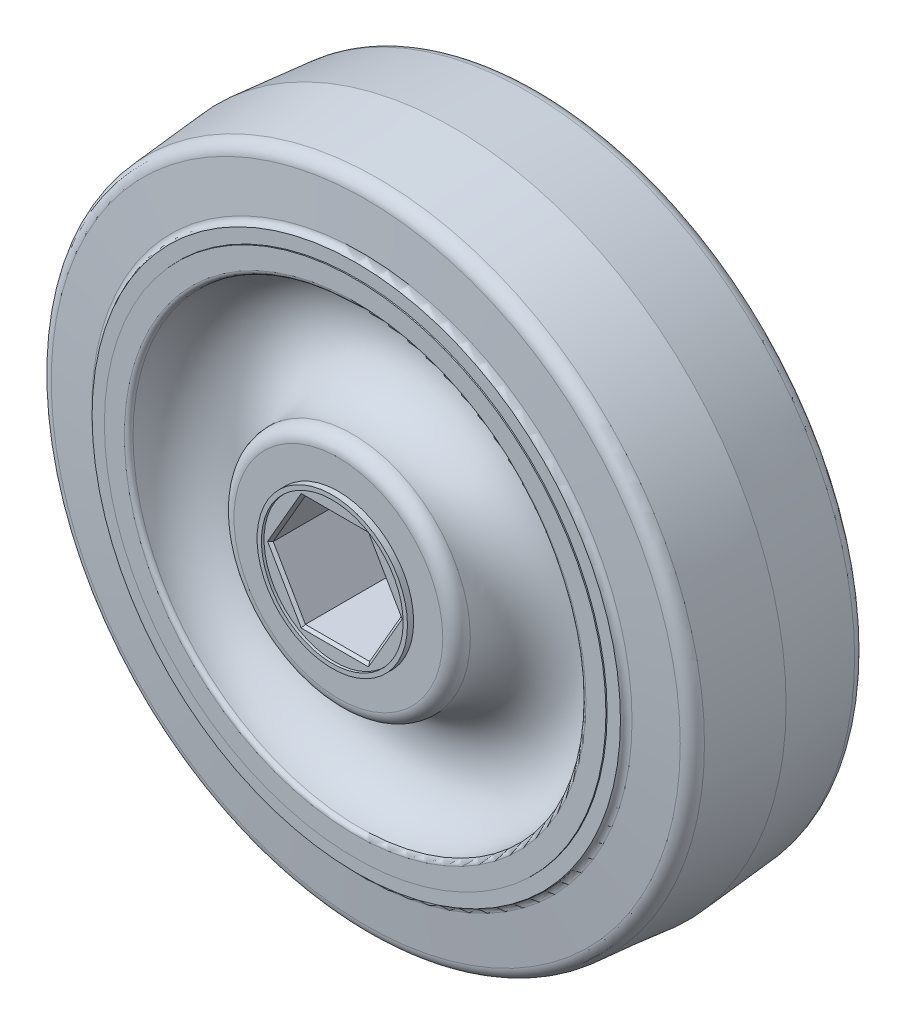
from build123d import *

# Parameters (mm, degrees)
SKETCH2_R           = 8.603491183
BOSS_EXTRUDE1_DEPTH = 0.70005
BOSS_EXTRUDE1_TAPER = 0.5
SKETCH3_R           = 8.603491183
BOSS_EXTRUDE2_DEPTH = 0.70005
BOSS_EXTRUDE2_TAPER = 0.5
CUT_EXTRUDE1_DEPTH  = 61.397248747
CHAMFER1_SIZE       = 0.3
FILLET1_R           = 0.508
FILLET2_R           = 1.524


with BuildPart() as part:
    # Sketch1 → Revolve1 (revolve)
    with BuildSketch(Plane(origin=(0, 0, 0), x_dir=(1, 0, 0), z_dir=(0, 1, 0))):
        with BuildLine():
            Line((13.789987667, 13.0937), (0, 13.0937))
            Line((0, 13.0937), (0, -13.0937))
            Line((0, -13.0937), (13.789987667, -13.0937))
            ThreePointArc((13.789987667, -13.0937), (18.693308011, -4.902723445), (25.889185204, -11.176))
            Line((25.889185204, -11.176), (28.673689588, -11.176))
            Line((28.673689588, -11.176), (28.92660953, -6.35))
            Line((28.92660953, -6.35), (28.9306, -6.35))
            Line((28.9306, -6.35), (28.684335845, -11.049))
            Line((28.684335845, -11.049), (30.208335845, -11.049))
            ThreePointArc((30.208335845, -11.049), (30.441334556, -10.611106234), (30.89449453, -10.409400044))
            Line((30.89449453, -10.409400044), (37.237849228, -9.854428419))
            Line((37.237849228, -9.854428419), (38.1, 0))
            Line((38.1, 0), (37.237849228, 9.854428419))
            Line((37.237849228, 9.854428419), (30.89449453, 10.409400044))
            ThreePointArc((30.89449453, 10.409400044), (30.441334556, 10.611106234), (30.208335845, 11.049))
            Line((30.208335845, 11.049), (28.684335845, 11.049))
            Line((28.684335845, 11.049), (28.9306, 6.35))
            Line((28.9306, 6.35), (28.92660953, 6.35))
            Line((28.92660953, 6.35), (28.673689588, 11.176))
            Line((28.673689588, 11.176), (25.889185204, 11.176))
            ThreePointArc((25.889185204, 11.176), (18.693308011, 4.902723445), (13.789987667, 13.0937))
        make_face()
    revolve(axis=Axis((0, 0, -13.0937), (0, 0, 1)))

    # Sketch2 → Boss-Extrude1 (add)
    with BuildSketch(Plane.XY.offset(13.0937)):
        Circle(SKETCH2_R)
    extrude(amount=BOSS_EXTRUDE1_DEPTH, taper=BOSS_EXTRUDE1_TAPER)

    # Sketch3 → Boss-Extrude2 (add)
    with BuildSketch(Plane(origin=(0, 0, -13.0937), x_dir=(-1, 0, 0), z_dir=(0, 0, -1))):
        Circle(SKETCH3_R)
    extrude(amount=BOSS_EXTRUDE2_DEPTH, taper=BOSS_EXTRUDE2_TAPER)

    # Sketch4 → Hole1 (revolve, cut)
    with BuildSketch(Plane(origin=(0, 0, 13.79375), x_dir=(0, -1, 0), z_dir=(1, 0, 0))):
        Polygon((0, 0), (0, 0.3), (8.1, 0.3), (8.10261806, 0), align=None)
    revolve(axis=Axis((0, 0, -96.20625), (0, 0, 1)), mode=Mode.SUBTRACT)

    # Sketch6 → Hole2 (revolve, cut)
    with BuildSketch(Plane(origin=(0, 0, -13.79375), x_dir=(0, 1, 0), z_dir=(1, 0, 0))):
        Polygon((0, 0), (0, 0.3), (8.1, 0.3), (8.10261806, 0), align=None)
    revolve(axis=Axis((0, 0, 96.20625), (0, 0, -1)), mode=Mode.SUBTRACT)

    # Sketch8 → Cut-Extrude1 (cut, through all)
    with BuildSketch(Plane(origin=(0, 0, -13.49375), x_dir=(-1, 0, 0), z_dir=(0, 0, -1))):
        Polygon((-7.347013116, 0), (-3.673506558, -6.3627), (3.673506558, -6.3627), (7.347013116, 0), (3.673506558, 6.3627), (-3.673506558, 6.3627), align=None)
    extrude(amount=-CUT_EXTRUDE1_DEPTH, mode=Mode.SUBTRACT)

    # Chamfer1
    chamfer1_edges = [part.edges().sort_by_distance(p)[0] for p in [
        (5.510259837, 3.18135, 13.49375),
        (0, 6.3627, 13.49375),
        (-5.510259837, 3.18135, 13.49375),
        (-5.510259837, -3.18135, 13.49375),
        (0, -6.3627, 13.49375),
        (5.510259837, -3.18135, 13.49375),
        (5.510259837, 3.18135, -13.49375),
        (5.510259837, -3.18135, -13.49375),
        (0, -6.3627, -13.49375),
        (-5.510259837, -3.18135, -13.49375),
        (-5.510259837, 3.18135, -13.49375),
        (0, 6.3627, -13.49375),
    ]]
    chamfer(chamfer1_edges, length=CHAMFER1_SIZE)

    # Fillet1
    fillet1_edges = [part.edges().sort_by_distance(p)[0] for p in [
        (-25.889185204, 0, 11.176),
        (-25.889185204, 0, -11.176),
    ]]
    fillet(fillet1_edges, radius=FILLET1_R)

    # Fillet2
    fillet2_edges = [part.edges().sort_by_distance(p)[0] for p in [
        (-13.789987667, 0, -13.0937),
        (-13.789987667, 0, 13.0937),
        (-37.237849228, 0, 9.854428419),
        (-37.237849228, 0, -9.854428419),
    ]]
    fillet(fillet2_edges, radius=FILLET2_R)


solid = part.part
